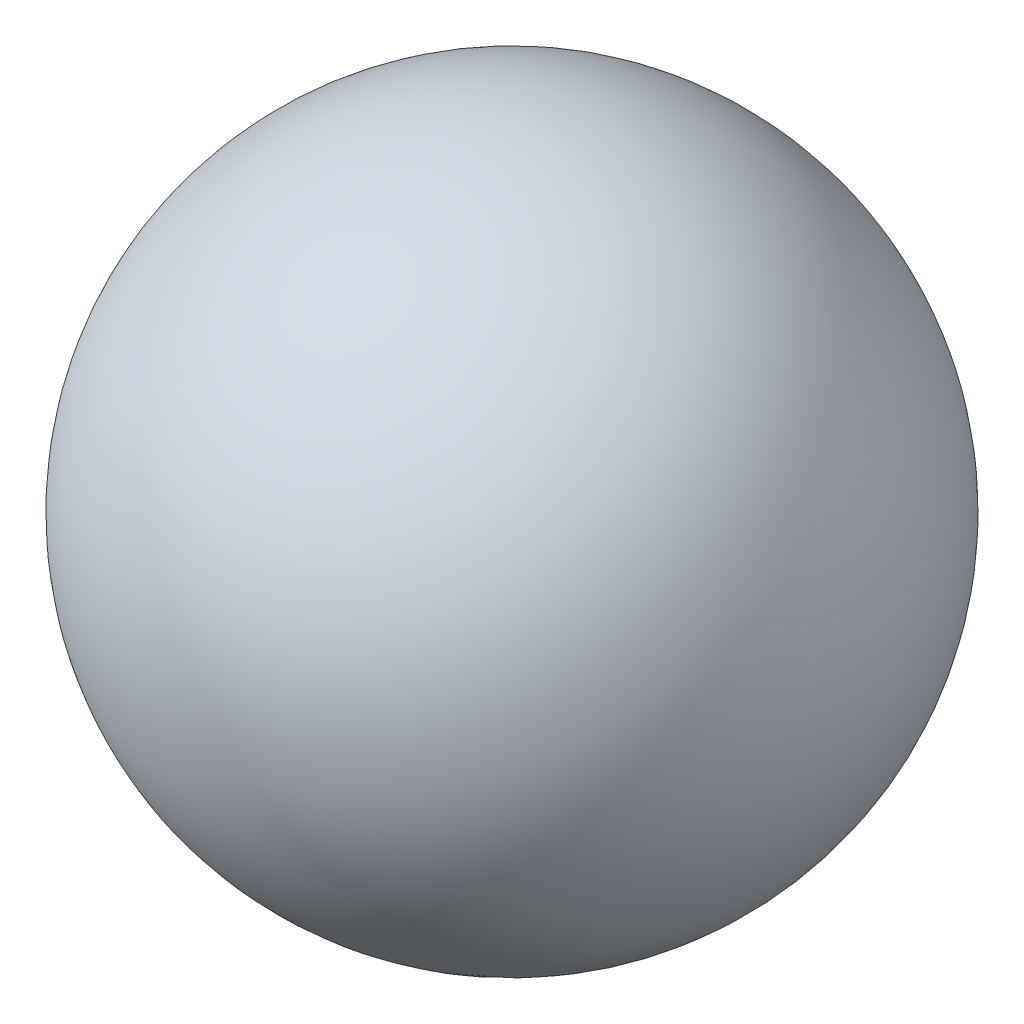
from build123d import *

# Parameters (mm, degrees)
SKETCH3_W          = 13
SKETCH3_H          = 25
CUT_EXTRUDE1_DEPTH = 27
FILLET1_R          = 4


with BuildPart() as part:
    # Sketch2 → Revolve1 (revolve)
    with BuildSketch(Plane(origin=(0, 0, 0), x_dir=(1, 0, 0), z_dir=(0, 1, 0))):
        with BuildLine():
            Line((0, -20), (0, 20))
            ThreePointArc((0, 20), (-20, 0), (0, -20))
        make_face()
    revolve(axis=Axis((0, 0, 20), (0, 0, -1)))

    # Sketch3 → Cut-Extrude1 (cut)
    with BuildSketch(Plane(origin=(0, 0, 0), x_dir=(1, 0, 0), z_dir=(0, 1, 0))):
        Rectangle(SKETCH3_W, SKETCH3_H)
    extrude(amount=-CUT_EXTRUDE1_DEPTH, mode=Mode.SUBTRACT)

    # Fillet1
    fillet1_edges = [part.edges().sort_by_distance(p)[0] for p in [
        (6.5, -7.097534783, -12.5),
        (6.5, -7.097534783, 12.5),
        (-6.5, -7.097534783, 12.5),
        (-6.5, -7.097534783, -12.5),
    ]]
    fillet(fillet1_edges, radius=FILLET1_R)


solid = part.part
